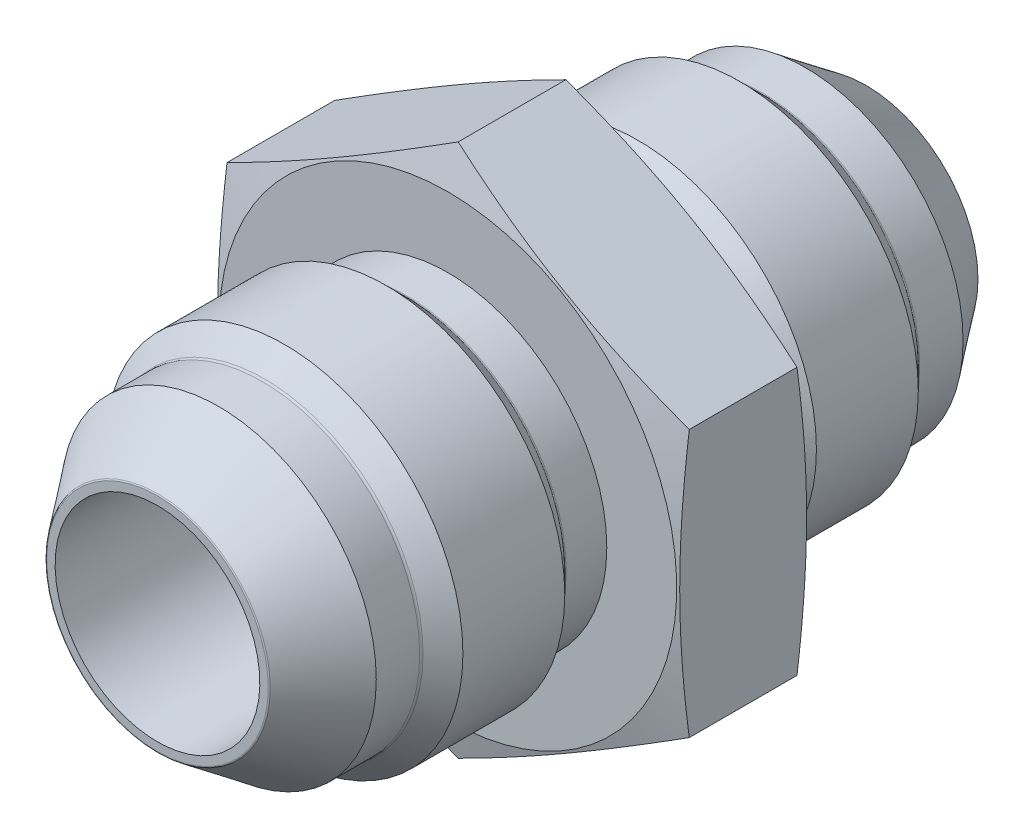
from build123d import *

# Parameters (mm, degrees)
CIRPATTERN1_COUNT   = 2
CIRPATTERN1_ANGLE   = 180
BOSS_EXTRUDE1_START = -4.8387
BOSS_EXTRUDE1_DEPTH = 9.6774
CIRPATTERN2_COUNT   = 2


with BuildPart() as part:
    # Sketch1 → Revolve1 (revolve)
    with BuildSketch(Plane(origin=(0, 0, 0), x_dir=(0, 0, -1), z_dir=(1, 0, 0))):
        with BuildLine():
            Line((-26.7843, 0), (0, 0))
            Line((0, 0), (0, 12.0015))
            Line((0, 12.0015), (-7.908489755, 12.0015))
            ThreePointArc((-7.908489755, 12.0015), (-8.005691347, 12.020834599), (-8.088094878, 12.075894878))
            Line((-8.088094878, 12.075894878), (-9.50595, 13.49375))
            Line((-9.50595, 13.49375), (-17.20215, 13.49375))
            Line((-17.20215, 13.49375), (-18.708905122, 11.986994878))
            ThreePointArc((-18.708905122, 11.986994878), (-18.791308653, 11.931934599), (-18.888510245, 11.9126))
            Line((-18.888510245, 11.9126), (-22.16644943, 11.9126))
            Line((-22.16644943, 11.9126), (-26.733730508, 8.470906846))
            ThreePointArc((-26.733730508, 8.470906846), (-26.770956664, 8.426147258), (-26.7843, 8.369480136))
            Line((-26.7843, 8.369480136), (-26.7843, 0))
        make_face()
    revolve(axis=Axis((0, 0, 19.812), (0, 0, -1)))


with BuildPart() as cirpattern1_1:
    # CirPattern1: pattern copy
    add(part.part.rotate(Axis((-10.4775, 0, 0), (1, 0, 0)), 1 * CIRPATTERN1_ANGLE / (CIRPATTERN1_COUNT - 1)))


with BuildPart() as part_1:
    add(part.part)

    add(cirpattern1_1.part)  # Boss-Extrude1 merges CirPattern1_1
    # Sketch4 → Boss-Extrude1 (add)
    with BuildSketch(Plane.XY.offset(BOSS_EXTRUDE1_START)):
        Polygon((0, 20.163958151), (-17.4625, 10.081979076), (-17.4625, -10.081979076), (0, -20.163958151), (17.4625, -10.081979076), (17.4625, 10.081979076), align=None)
    extrude(amount=BOSS_EXTRUDE1_DEPTH)

    # Sketch5 → Cut-Revolve1 (revolve, cut)
    with BuildSketch(Plane(origin=(0, 0, 0), x_dir=(0, 0, -1), z_dir=(1, 0, 0))):
        Polygon((-4.8387, 23.043216303), (4.8387, 23.043216303), (4.8387, 17.2847), (4.067205104, 20.163958151), (-4.067205104, 20.163958151), (-4.8387, 17.2847), align=None)
    revolve(axis=Axis((0, 0, 4.8387), (0, 0, -1)), mode=Mode.SUBTRACT)

    # Sketch6 → Cut-Revolve2 (revolve, cut)
    with BuildSketch(Plane(origin=(0, 0, 0), x_dir=(0, 0, -1), z_dir=(1, 0, 0))):
        with BuildLine():
            Line((-26.7843, 7.7343), (0, 7.7343))
            ThreePointArc((0, 7.7343), (5.468975978, 5.468975978), (7.7343, 0))
            Line((7.7343, 0), (-26.7843, 0))
            Line((-26.7843, 0), (-26.7843, 7.7343))
        make_face()
    cut_revolve2 = revolve(axis=Axis((0, 0, -7.7343), (0, 0, 1)), mode=Mode.SUBTRACT)

    # CirPattern2: Cut-Revolve2 ×2 about axis
    cirpattern2_axis = Axis((-10.4775, 0, 0), (1, 0, 0))
    for i in range(1, CIRPATTERN2_COUNT):
        add(cut_revolve2.rotate(cirpattern2_axis, i * 360 / CIRPATTERN2_COUNT), mode=Mode.SUBTRACT)


solid = part_1.part
